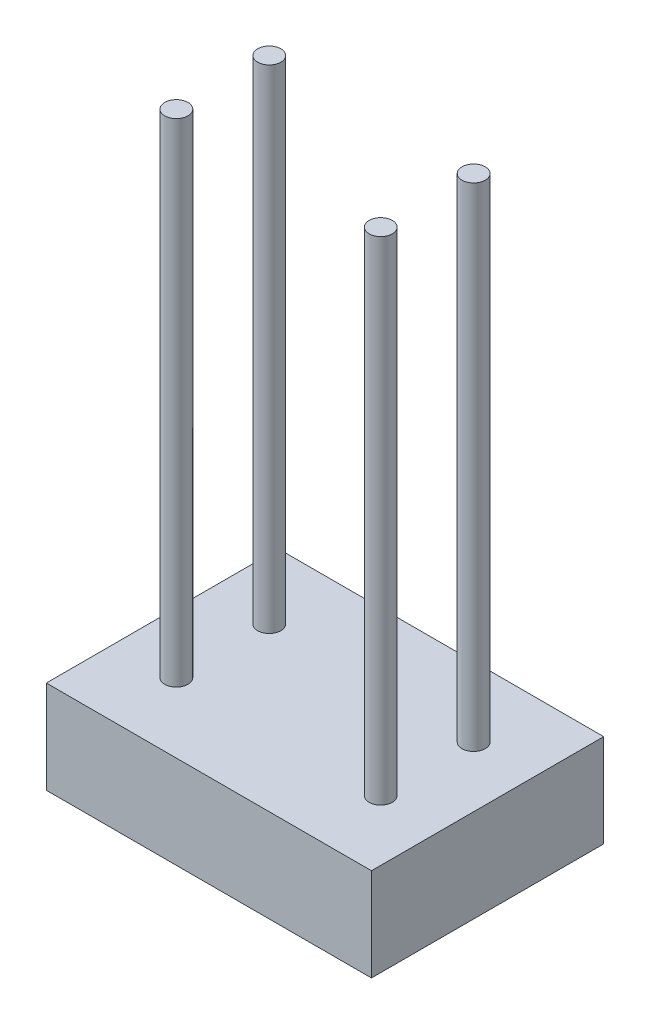
from build123d import *

# Parameters (mm, degrees)
SKETCH1_W           = 350
SKETCH1_H           = 250
BOSS_EXTRUDE1_DEPTH = 100
SKETCH3_R           = 12.5
BOSS_EXTRUDE2_DEPTH = 530


with BuildPart() as part:
    # Sketch1 → Boss-Extrude1 (new body)
    with BuildSketch(Plane(origin=(0, 0, 0), x_dir=(1, 0, 0), z_dir=(0, 1, 0))):
        Rectangle(SKETCH1_W, SKETCH1_H)
    extrude(amount=BOSS_EXTRUDE1_DEPTH)

    # Sketch3 → Boss-Extrude2 (add)
    with BuildSketch(Plane(origin=(0, 100, 0), x_dir=(1, 0, 0), z_dir=(0, 1, 0))):
        with Locations((-110, 50)):
            Circle(SKETCH3_R)
        with Locations((110, 50)):
            Circle(SKETCH3_R)
        with Locations((110, -50)):
            Circle(SKETCH3_R)
        with Locations((-110, -50)):
            Circle(SKETCH3_R)
    extrude(amount=BOSS_EXTRUDE2_DEPTH)


solid = part.part
